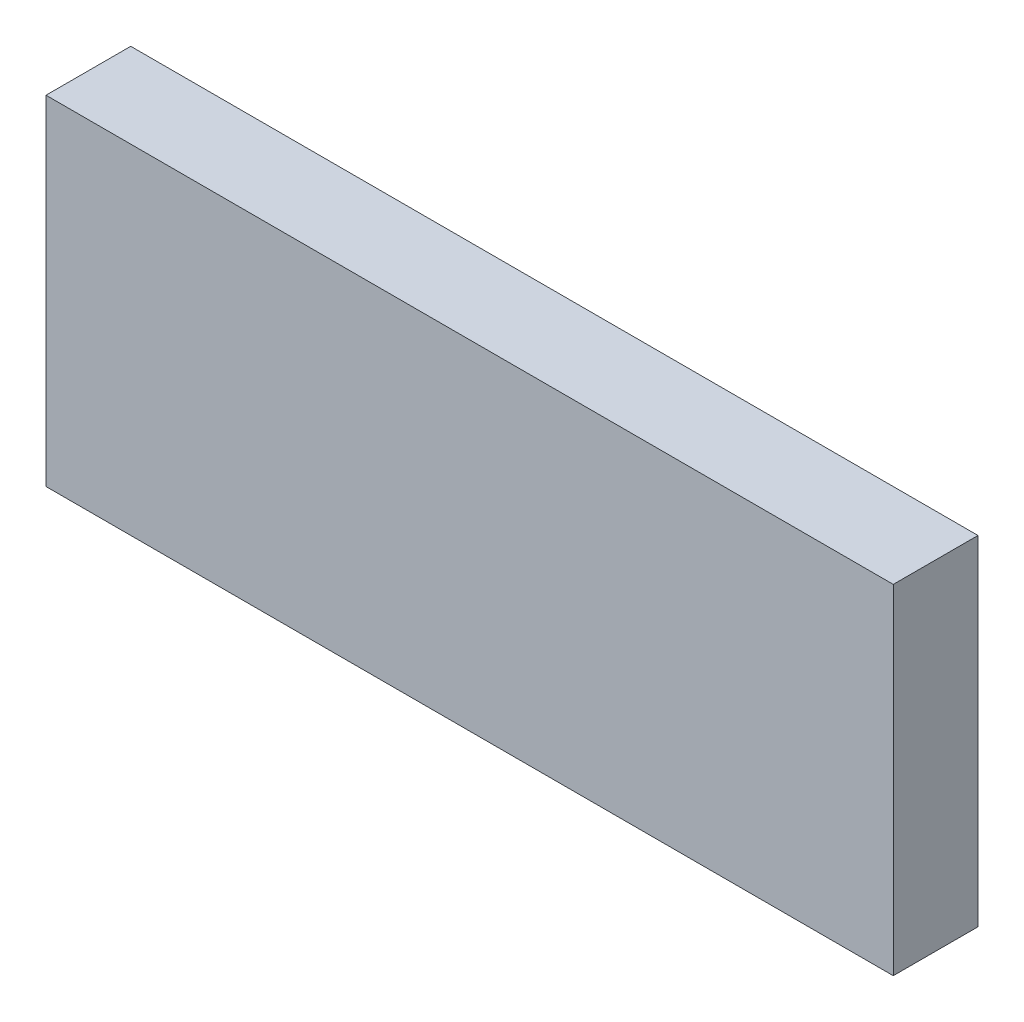
from build123d import *

# Parameters (mm, degrees)
SKETCH2_W           = 50
SKETCH2_H           = 20
BOSS_EXTRUDE1_DEPTH = 5


with BuildPart() as part:
    # Sketch2 → Boss-Extrude1 (new body)
    with BuildSketch(Plane.XY):
        with Locations((25, -10)):
            Rectangle(SKETCH2_W, SKETCH2_H)
    extrude(amount=BOSS_EXTRUDE1_DEPTH)


solid = part.part
